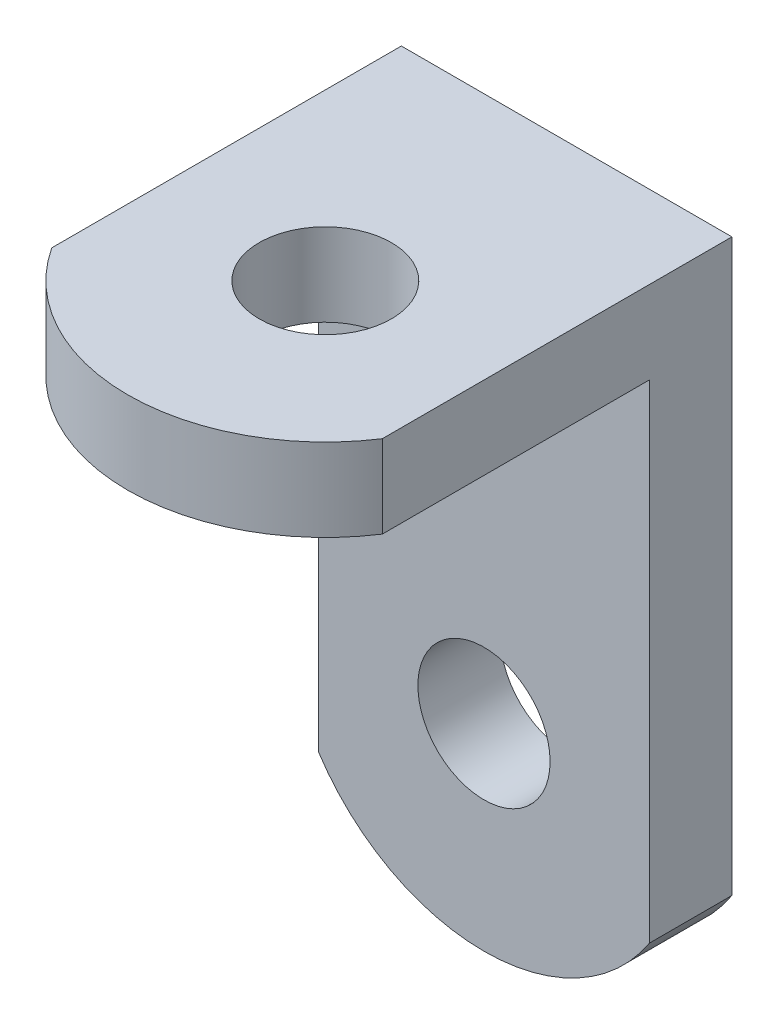
from build123d import *

# Parameters (mm, degrees)
SKETCH1_W           = 12.7
SKETCH1_H           = 16.891
BOSS_EXTRUDE1_DEPTH = 3.175
SKETCH2_R           = 2.54
CUT_EXTRUDE1_DEPTH  = 4.175
SKETCH3_W           = 12.7
SKETCH3_H           = 3.175
BOSS_EXTRUDE2_DEPTH = 22.225
SKETCH4_R           = 2.54
CUT_EXTRUDE2_DEPTH  = 4.175
CUT_EXTRUDE3_DEPTH  = 4.175
CUT_EXTRUDE4_DEPTH  = 4.175


with BuildPart() as part:
    # Sketch1 → Boss-Extrude1 (new body)
    with BuildSketch(Plane(origin=(0, 0, 0), x_dir=(1, 0, 0), z_dir=(0, 1, 0))):
        with Locations((-16.427296288, 6.362973118)):
            Rectangle(SKETCH1_W, SKETCH1_H)
    extrude(amount=BOSS_EXTRUDE1_DEPTH)

    # Sketch2 → Cut-Extrude1 (cut, through all)
    with BuildSketch(Plane(origin=(0, 3.175, 0), x_dir=(1, 0, 0), z_dir=(0, 1, 0))):
        with Locations((-16.427296288, 5.537473118)):
            Circle(SKETCH2_R)
    extrude(amount=-CUT_EXTRUDE1_DEPTH, mode=Mode.SUBTRACT)

    # Sketch3 → Boss-Extrude2 (add)
    with BuildSketch(Plane.XZ):
        with Locations((-16.427296288, -13.220973118)):
            Rectangle(SKETCH3_W, SKETCH3_H)
    extrude(amount=BOSS_EXTRUDE2_DEPTH)

    # Sketch4 → Cut-Extrude2 (cut, through all)
    with BuildSketch(Plane.XY.offset(-11.633473118)):
        with Locations((-16.427296288, -14.605)):
            Circle(SKETCH4_R)
    extrude(amount=-CUT_EXTRUDE2_DEPTH, mode=Mode.SUBTRACT)

    # Sketch6 → Cut-Extrude3 (cut, through all)
    with BuildSketch(Plane.XY.offset(-11.633473118)):
        with BuildLine():
            Line((-10.077296288, -22.225), (-22.777296288, -22.225))
            Line((-22.777296288, -22.225), (-22.777296288, -18.739929724))
            ThreePointArc((-22.777296288, -18.739929724), (-16.427296288, -22.182608054), (-10.077296288, -18.739929724))
            Line((-10.077296288, -18.739929724), (-10.077296288, -22.225))
        make_face()
    extrude(amount=-CUT_EXTRUDE3_DEPTH, mode=Mode.SUBTRACT)

    # Sketch7 → Cut-Extrude4 (cut, through all)
    with BuildSketch(Plane.XZ):
        with BuildLine():
            Line((-22.777296288, -1.376737497), (-22.777296288, 2.082526882))
            Line((-22.777296288, 2.082526882), (-10.077296288, 2.082526882))
            Line((-10.077296288, 2.082526882), (-10.077296288, -1.376737497))
            ThreePointArc((-10.077296288, -1.376737497), (-16.427296288, 2.054247432), (-22.777296288, -1.376737497))
        make_face()
    extrude(amount=-CUT_EXTRUDE4_DEPTH, mode=Mode.SUBTRACT)


solid = part.part
